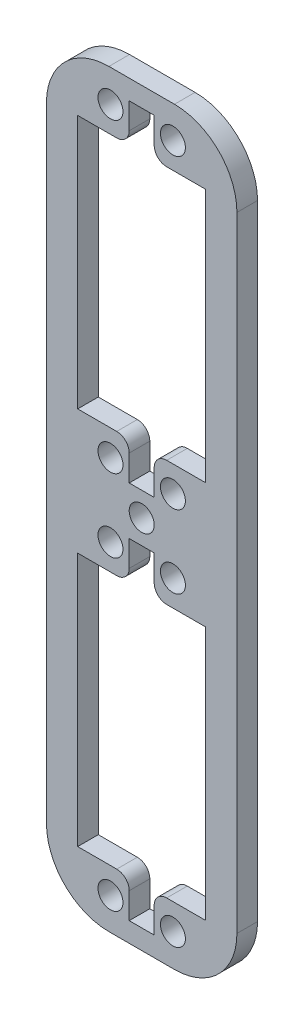
from build123d import *

# Parameters (mm, degrees)
SKETCH2_R           = 2
BOSS_EXTRUDE1_DEPTH = 1.65


with BuildPart() as part:
    # Sketch2 → Boss-Extrude1 (new body, symmetric)
    with BuildSketch(Plane.XY):
        with BuildLine():
            Line((-5.25, -60), (5.25, -60))
            ThreePointArc((5.25, -60), (12.321067812, -57.071067812), (15.25, -50))
            Line((15.25, -50), (15.25, 50))
            ThreePointArc((15.25, 50), (12.321067812, 57.071067812), (5.25, 60))
            Line((5.25, 60), (-5.25, 60))
            ThreePointArc((-5.25, 60), (-12.321067812, 57.071067812), (-15.25, 50))
            Line((-15.25, 50), (-15.25, -50))
            ThreePointArc((-15.25, -50), (-12.321067812, -57.071067812), (-5.25, -60))
        make_face()
        Circle(SKETCH2_R, mode=Mode.SUBTRACT)
        with Locations((5, 5.85)):
            Circle(SKETCH2_R, mode=Mode.SUBTRACT)
        with Locations((5, -5.85)):
            Circle(SKETCH2_R, mode=Mode.SUBTRACT)
        with Locations((-5, -5.85)):
            Circle(SKETCH2_R, mode=Mode.SUBTRACT)
        with Locations((-5, 5.85)):
            Circle(SKETCH2_R, mode=Mode.SUBTRACT)
        with Locations((5, 54.85)):
            Circle(SKETCH2_R, mode=Mode.SUBTRACT)
        with Locations((5, -54.85)):
            Circle(SKETCH2_R, mode=Mode.SUBTRACT)
        with Locations((-5, -54.85)):
            Circle(SKETCH2_R, mode=Mode.SUBTRACT)
        with Locations((-5, 54.85)):
            Circle(SKETCH2_R, mode=Mode.SUBTRACT)
        with BuildLine():
            Line((-10.25, 50.7), (-4, 50.7))
            ThreePointArc((-4, 50.7), (-2.585786438, 51.285786438), (-2, 52.7))
            Line((-2, 52.7), (-2, 56.85))
            Line((-2, 56.85), (2, 56.85))
            Line((2, 56.85), (2, 52.7))
            ThreePointArc((2, 52.7), (2.585786438, 51.285786438), (4, 50.7))
            Line((4, 50.7), (10.25, 50.7))
            Line((10.25, 50.7), (10.25, 10))
            Line((10.25, 10), (4, 10))
            ThreePointArc((4, 10), (2.585786438, 9.414213562), (2, 8))
            Line((2, 8), (2, 3.85))
            Line((2, 3.85), (-2, 3.85))
            Line((-2, 3.85), (-2, 8))
            ThreePointArc((-2, 8), (-2.585786438, 9.414213562), (-4, 10))
            Line((-4, 10), (-10.25, 10))
            Line((-10.25, 10), (-10.25, 50.7))
        make_face(mode=Mode.SUBTRACT)
        with BuildLine():
            Line((-10.25, -50.7), (-4, -50.7))
            ThreePointArc((-4, -50.7), (-2.585786438, -51.285786438), (-2, -52.7))
            Line((-2, -52.7), (-2, -56.85))
            Line((-2, -56.85), (2, -56.85))
            Line((2, -56.85), (2, -52.7))
            ThreePointArc((2, -52.7), (2.585786438, -51.285786438), (4, -50.7))
            Line((4, -50.7), (10.25, -50.7))
            Line((10.25, -50.7), (10.25, -10))
            Line((10.25, -10), (4, -10))
            ThreePointArc((4, -10), (2.585786438, -9.414213562), (2, -8))
            Line((2, -8), (2, -3.85))
            Line((2, -3.85), (-2, -3.85))
            Line((-2, -3.85), (-2, -8))
            ThreePointArc((-2, -8), (-2.585786438, -9.414213562), (-4, -10))
            Line((-4, -10), (-10.25, -10))
            Line((-10.25, -10), (-10.25, -50.7))
        make_face(mode=Mode.SUBTRACT)
    extrude(amount=BOSS_EXTRUDE1_DEPTH, both=True)


solid = part.part
